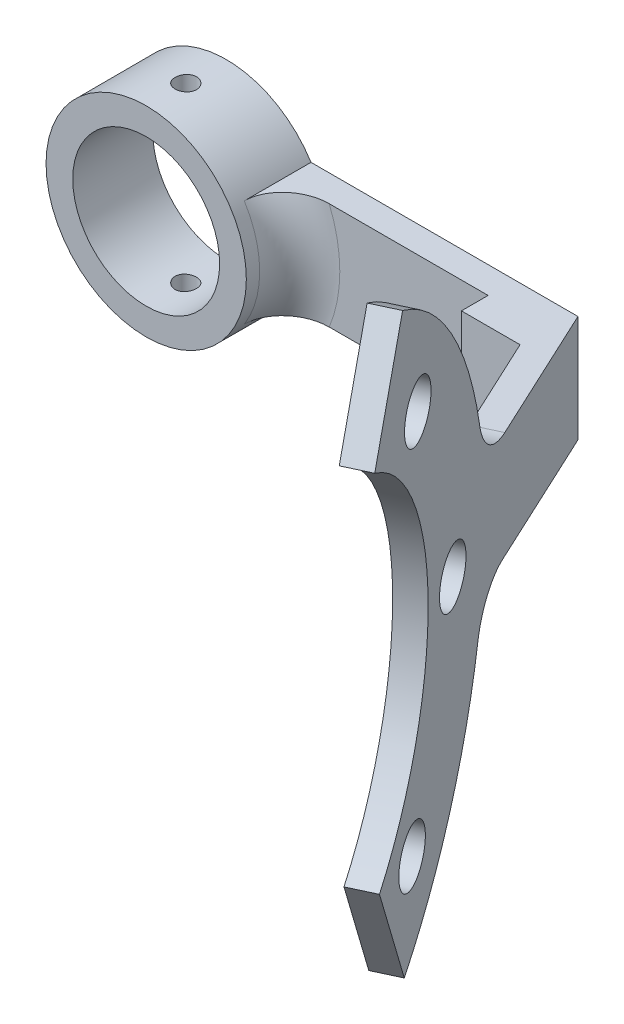
from build123d import *

# Parameters (mm, degrees)
BOSS_EXTRUDE1_DEPTH     = 8
BOSS_EXTRUDE2_DEPTH     = 2
SKETCH3_R               = 2.05
CUT_EXTRUDE3_DEPTH      = 10
CUT_EXTRUDE3_DEPTH_BACK = 10
FILLET2_R               = 4
SKETCH6_R               = 7.5
BOSS_EXTRUDE3_DEPTH     = 6
SKETCH2_R               = 5.5
CUT_EXTRUDE4_DEPTH      = 28.361360249
CUT_EXTRUDE4_DEPTH_BACK = 3
SKETCH8_R               = 0.8
CUT_EXTRUDE5_DEPTH      = 30.928860828
FILLET3_R               = 3


with BuildPart() as part:
    # Sketch1 → Boss-Extrude1 (new body)
    with BuildSketch(Plane(origin=(0, 0, 0), x_dir=(1, 0, 0), z_dir=(0, 1, 0))):
        Polygon((0, 0), (0, 2), (26.334414729, 2), (34.518104392, -15.549979118), (32.760161227, -16.503727422), (25.996962058, -2), (21.605779457, -2), (21.605779457, 0), align=None)
    extrude(amount=BOSS_EXTRUDE1_DEPTH)

    # Sketch5 → Boss-Extrude2 (add)
    with BuildSketch(Plane(origin=(22.396969556, 0, -10.443878423), x_dir=(-0.422618262, 0, -0.906307787), z_dir=(0.906307787, 0, -0.422618262))):
        with BuildLine():
            Line((-40.780850255, 18.736062391), (-36.467218683, 26.428860828))
            ThreePointArc((-36.467218683, 26.428860828), (-23.692308478, 4.771999965), (-36.205658542, -17.037035395))
            Line((-36.205658542, -17.037035395), (-40.049339329, -9.057253488))
            ThreePointArc((-40.049339329, -9.057253488), (-32.517126315, 5.047276383), (-40.780850255, 18.736062391))
        make_face()
    extrude(amount=-BOSS_EXTRUDE2_DEPTH)

    # Sketch3 → Cut-Extrude3 (cut, two sides)
    with BuildSketch(Plane(origin=(20.587699136, 0, -9.600201771), x_dir=(0.422618262, 0, 0.906307787), z_dir=(-0.906307787, 0, 0.422618262))) as cut_extrude3_sk:
        with Locations((28.701516689, 4)):
            Circle(SKETCH3_R)
        with Locations((34.117040182, 18.317355913)):
            Circle(SKETCH3_R)
        with Locations((48.070293023, 24.611901983)):
            Circle(SKETCH3_R)
        with Locations((62.387648936, 19.19637849)):
            Circle(SKETCH3_R)
        with Locations((68.682195005, 5.243125649)):
            Circle(SKETCH3_R)
        with Locations((63.266671512, -9.074230264)):
            Circle(SKETCH3_R)
        with Locations((49.313418672, -15.368776333)):
            Circle(SKETCH3_R)
        with Locations((34.996062759, -9.953252841)):
            Circle(SKETCH3_R)
    extrude(amount=CUT_EXTRUDE3_DEPTH, mode=Mode.SUBTRACT)
    extrude(cut_extrude3_sk.sketch, amount=-CUT_EXTRUDE3_DEPTH_BACK, mode=Mode.SUBTRACT)

    # Fillet2
    fillet2_edges = [part.edges().sort_by_distance(p)[0] for p in [
        (31.687047343, 0, 11.840592477),
        (31.60186373, 8, 11.657915631),
    ]]
    fillet(fillet2_edges, radius=FILLET2_R)

    # Sketch6 → Boss-Extrude3 (add)
    with BuildSketch(Plane(origin=(0, 0, -2), x_dir=(-1, 0, 0), z_dir=(0, 0, -1))):
        with Locations((0, 4)):
            Circle(SKETCH6_R)
    extrude(amount=-BOSS_EXTRUDE3_DEPTH)

    # Sketch2 → Cut-Extrude4 (cut, two sides)
    with BuildSketch(Plane.XY) as cut_extrude4_sk:
        with Locations((0, 4)):
            Circle(SKETCH2_R)
    extrude(amount=CUT_EXTRUDE4_DEPTH, mode=Mode.SUBTRACT)
    extrude(cut_extrude4_sk.sketch, amount=-CUT_EXTRUDE4_DEPTH_BACK, mode=Mode.SUBTRACT)

    # Sketch8 → Cut-Extrude5 (cut, through all)
    with BuildSketch(Plane(origin=(0, -3.5, 0), x_dir=(-1, 0, 0), z_dir=(0, -1, 0))):
        with Locations((0, -1.034043254)):
            Circle(SKETCH8_R)
    extrude(amount=-CUT_EXTRUDE5_DEPTH, mode=Mode.SUBTRACT)

    # Fillet3
    fillet3_edges = [part.edges().sort_by_distance(p)[0] for p in [
        (7.5, 4, 0),
    ]]
    fillet(fillet3_edges, radius=FILLET3_R)


solid = part.part
